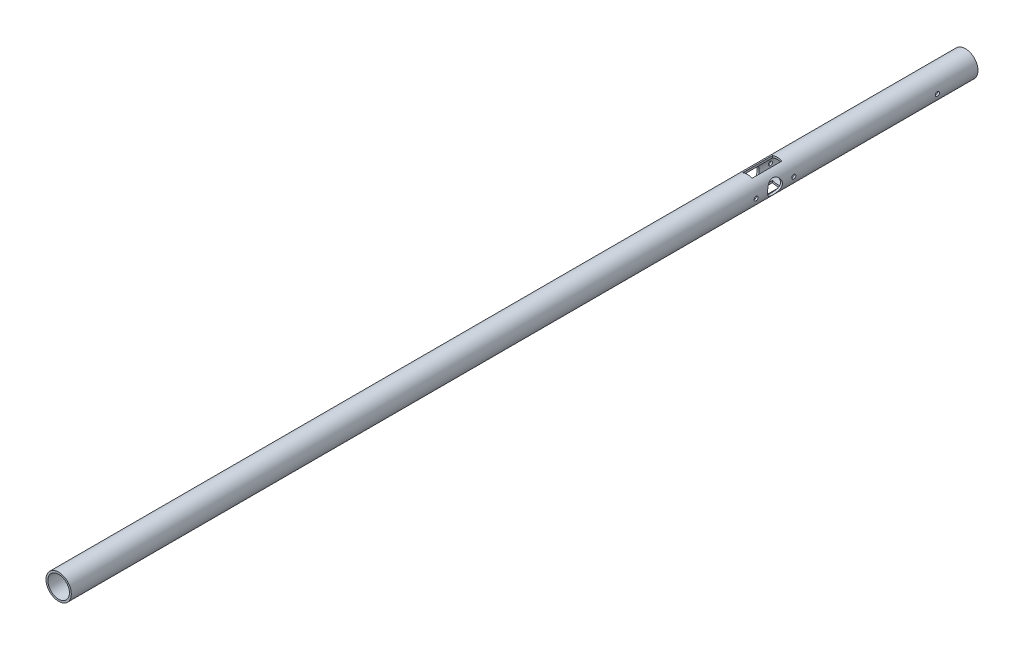
from build123d import *

# Parameters (mm, degrees)
SKETCH1_R           = 9.36
SKETCH1_R_2         = 7.99
EXTRUDE1_DEPTH      = 670
EXTRUDE2_DEPTH      = 671.13074784
EXTRUDE2_DEPTH_BACK = 671.13074784
SKETCH2_R           = 1.5
SKETCH2_R_2         = 5.5
EXTRUDE3_DEPTH      = 25
EXTRUDE3_DEPTH_BACK = 25
SKETCH3_W           = 7
SKETCH3_H           = 22


with BuildPart() as part:
    # Sketch1 → Extrude1 (new body)
    with BuildSketch(Plane.XY):
        Circle(SKETCH1_R)
        Circle(SKETCH1_R_2, mode=Mode.SUBTRACT)
    extrude(amount=EXTRUDE1_DEPTH)

    # Sketch2 → Extrude2 (cut, two sides: drawn at the far end of the back side and taken through both)
    with BuildSketch(Plane(origin=(0, 0, 0), x_dir=(0, 0, -1), z_dir=(1, 0, 0)).offset(-EXTRUDE2_DEPTH_BACK)):
        with Locations((-30, 0)):
            Circle(SKETCH2_R)
        with Locations((-150, 0)):
            Circle(SKETCH2_R_2)
        with Locations((-136.0625, 0)):
            Circle(SKETCH2_R)
        with Locations((-163.9375, 0)):
            Circle(SKETCH2_R)
    extrude(amount=EXTRUDE2_DEPTH + EXTRUDE2_DEPTH_BACK, mode=Mode.SUBTRACT)

    # Sketch3 → Extrude3 (cut, two sides: drawn at the far end of the back side and taken through both)
    with BuildSketch(Plane(origin=(0, 0, 0), x_dir=(1, 0, 0), z_dir=(0, 1, 0)).offset(-EXTRUDE3_DEPTH_BACK)):
        with Locations((0, -150)):
            Rectangle(SKETCH3_W, SKETCH3_H)
    extrude(amount=EXTRUDE3_DEPTH + EXTRUDE3_DEPTH_BACK, mode=Mode.SUBTRACT)


solid = part.part
